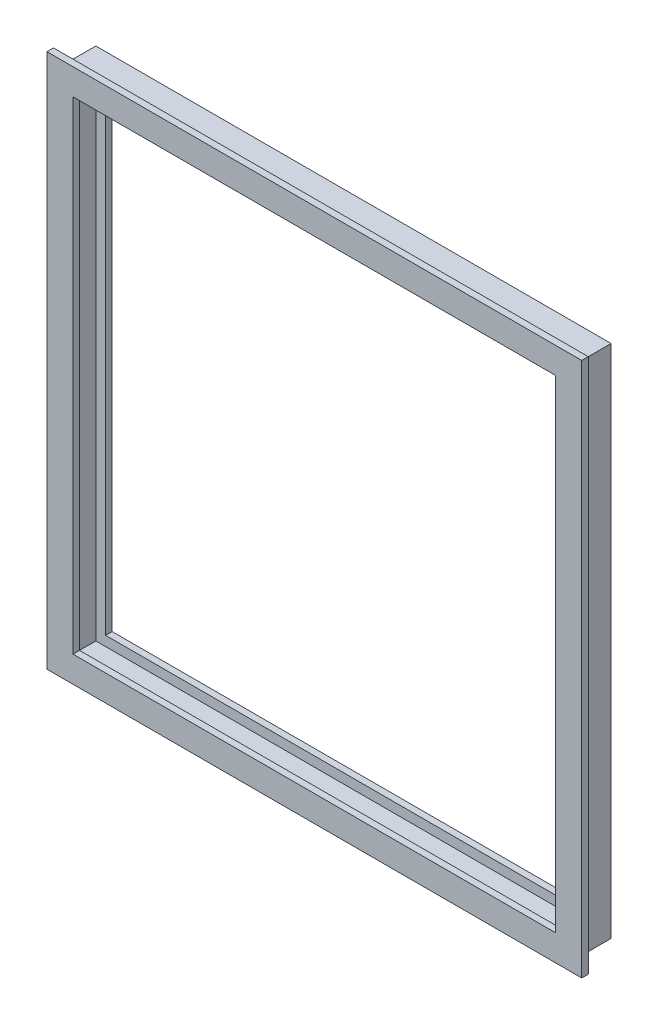
from build123d import *


with BuildPart() as part:
    # Sweep1: sweep along a path in Sketch2
    with BuildLine(Plane.XY) as sweep1_path:
        Line((125.4125, -125.4125), (-125.4125, -125.4125))
        Line((-125.4125, -125.4125), (-125.4125, 125.4125))
        Line((-125.4125, 125.4125), (125.4125, 125.4125))
        Line((125.4125, 125.4125), (125.4125, -125.4125))
    # Sketch1 → Sweep1 (sweep)
    with BuildSketch(Plane(origin=(0, 0, 0), x_dir=(1, 0, 0), z_dir=(0, 1, 0))):
        Polygon((-125.4125, 7.9375), (-125.4125, -7.9375), (-130.175, -7.9375), (-130.175, -11.1125), (-117.475, -11.1125), (-117.475, -7.9375), (-122.2375, -7.9375), (-122.2375, 4.7625), (-117.475, 4.7625), (-117.475, 7.9375), align=None)
    sweep(path=sweep1_path.line, transition=Transition.RIGHT)


solid = part.part
